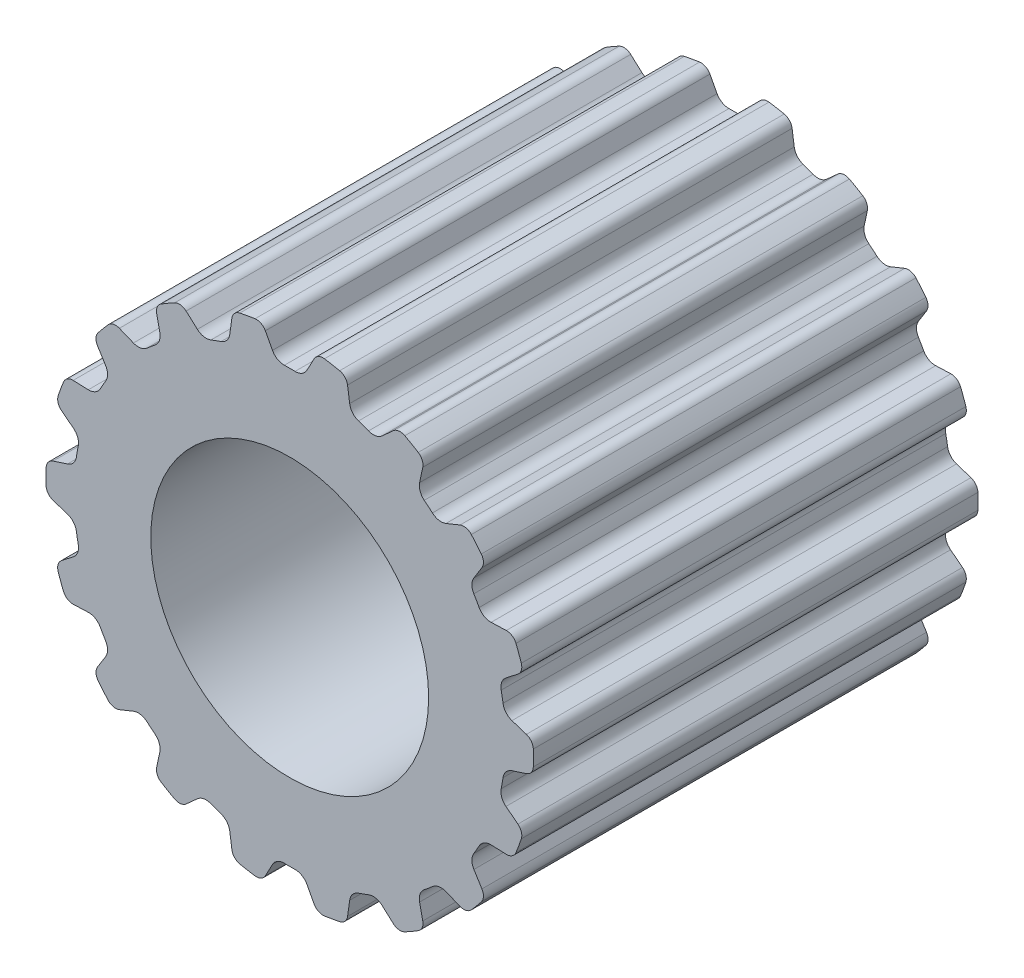
from build123d import *

# Parameters (mm, degrees)
SKETCH1_R                = 5.57
BOSS_EXTRUDE1_DEPTH      = 5.08
CUT_EXTRUDE1_DEPTH       = 11.16
FILLET1_R                = 0.23
FILLET2_R                = 0.3
CIRPATTERN1_COUNT        = 18
FILLET1_OF_CIRPATTERN1_R = 0.23
FILLET2_OF_CIRPATTERN1_R = 0.3
SKETCH3_R                = 3.175
CUT_EXTRUDE2_DEPTH       = 11.16


with BuildPart() as part:
    # Sketch1 → Boss-Extrude1 (new body, symmetric)
    with BuildSketch(Plane.XY):
        Circle(SKETCH1_R)
    extrude(amount=BOSS_EXTRUDE1_DEPTH, both=True)

    # Sketch2 → Cut-Extrude1 (cut, through all)
    with BuildSketch(Plane.XY.offset(5.08)):
        with BuildLine():
            Line((0.3050032, 4.920556173), (0.631238645, 5.534115808))
            ThreePointArc((0.631238645, 5.534115808), (0, 5.57), (-0.631238645, 5.534115808))
            Line((-0.631238645, 5.534115808), (-0.3050032, 4.920556173))
            ThreePointArc((-0.3050032, 4.920556173), (0, 4.93), (0.3050032, 4.920556173))
        make_face()
    cut_extrude1 = extrude(amount=-CUT_EXTRUDE1_DEPTH, mode=Mode.SUBTRACT)

    # Fillet1
    fillet1_edges = [part.edges().sort_by_distance(p)[0] for p in [
        (-0.631238645, 5.534115808, 0),
        (0.631238645, 5.534115808, 0),
    ]]
    fillet(fillet1_edges, radius=FILLET1_R)

    # Fillet2
    fillet2_edges = [part.edges().sort_by_distance(p)[0] for p in [
        (-0.3050032, 4.920556173, 0),
        (0.3050032, 4.920556173, 0),
    ]]
    fillet(fillet2_edges, radius=FILLET2_R)

    # CirPattern1: Cut-Extrude1 ×18 about axis
    cirpattern1_axis = Axis((0, 0, 0), (0, 0, 1))
    for i in range(1, CIRPATTERN1_COUNT):
        add(cut_extrude1.rotate(cirpattern1_axis, i * 360 / CIRPATTERN1_COUNT), mode=Mode.SUBTRACT)

    # Fillet1 of CirPattern1
    fillet1_of_cirpattern1_edges = [part.edges().sort_by_distance(p)[0] for p in [
        (-2.485949378, 4.984471455, 0),
        (-1.299608785, 5.416264119, 0),
        (-4.040817928, 3.833626282, 0),
        (-3.073704216, 4.645131042, 0),
        (-5.108304199, 2.220389202, 0),
        (-4.477065555, 3.313726606, 0),
        (-5.559653594, 0.339340414, 0),
        (-5.340426713, 1.582637836, 0),
        (-5.340426713, -1.582637836, 0),
        (-5.559653594, -0.339340414, 0),
        (-4.477065555, -3.313726606, 0),
        (-5.108304199, -2.220389202, 0),
        (-3.073704216, -4.645131042, 0),
        (-4.040817928, -3.833626282, 0),
        (-1.299608785, -5.416264119, 0),
        (-2.485949378, -4.984471455, 0),
        (0.631238645, -5.534115808, 0),
        (-0.631238645, -5.534115808, 0),
        (2.485949378, -4.984471455, 0),
        (1.299608785, -5.416264119, 0),
        (4.040817928, -3.833626282, 0),
        (3.073704216, -4.645131042, 0),
        (5.108304199, -2.220389202, 0),
        (4.477065555, -3.313726606, 0),
        (5.559653594, -0.339340414, 0),
        (5.340426713, -1.582637836, 0),
        (5.340426713, 1.582637836, 0),
        (5.559653594, 0.339340414, 0),
        (4.477065555, 3.313726606, 0),
        (5.108304199, 2.220389202, 0),
        (3.073704216, 4.645131042, 0),
        (4.040817928, 3.833626282, 0),
        (1.299608785, 5.416264119, 0),
        (2.485949378, 4.984471455, 0),
    ]]
    fillet(fillet1_of_cirpattern1_edges, radius=FILLET1_OF_CIRPATTERN1_R)

    # Fillet2 of CirPattern1
    fillet2_of_cirpattern1_edges = [part.edges().sort_by_distance(p)[0] for p in [
        (-1.969538584, 4.519493087, 0),
        (-1.396320071, 4.728127564, 0),
        (-3.396518547, 3.573312435, 0),
        (-2.929226534, 3.965416991, 0),
        (-4.413828246, 2.196137567, 0),
        (-4.108825046, 2.724418606, 0),
        (-4.898765118, 0.554076096, 0),
        (-4.792838618, 1.154815129, 0),
        (-4.792838618, -1.154815129, 0),
        (-4.898765118, -0.554076096, 0),
        (-4.108825046, -2.724418606, 0),
        (-4.413828246, -2.196137567, 0),
        (-2.929226534, -3.965416991, 0),
        (-3.396518547, -3.573312435, 0),
        (-1.396320071, -4.728127564, 0),
        (-1.969538584, -4.519493087, 0),
        (0.3050032, -4.920556173, 0),
        (-0.3050032, -4.920556173, 0),
        (1.969538584, -4.519493087, 0),
        (1.396320071, -4.728127564, 0),
        (3.396518547, -3.573312435, 0),
        (2.929226534, -3.965416991, 0),
        (4.413828246, -2.196137567, 0),
        (4.108825046, -2.724418606, 0),
        (4.898765118, -0.554076096, 0),
        (4.792838618, -1.154815129, 0),
        (4.792838618, 1.154815129, 0),
        (4.898765118, 0.554076096, 0),
        (4.108825046, 2.724418606, 0),
        (4.413828246, 2.196137567, 0),
        (2.929226534, 3.965416991, 0),
        (3.396518547, 3.573312435, 0),
        (1.396320071, 4.728127564, 0),
        (1.969538584, 4.519493087, 0),
    ]]
    fillet(fillet2_of_cirpattern1_edges, radius=FILLET2_OF_CIRPATTERN1_R)

    # Sketch3 → Cut-Extrude2 (cut, through all)
    with BuildSketch(Plane.XY.offset(5.08)):
        Circle(SKETCH3_R)
    extrude(amount=-CUT_EXTRUDE2_DEPTH, mode=Mode.SUBTRACT)


solid = part.part
